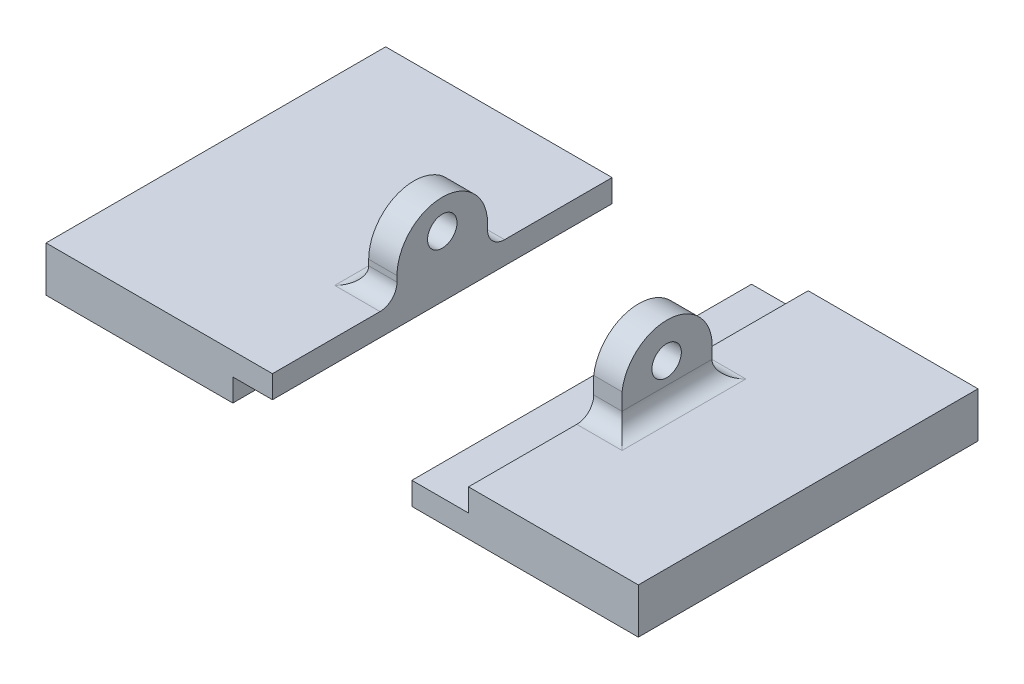
from build123d import *

# Parameters (mm, degrees)
SKETCH1_W             = 20
SKETCH1_H             = 30
BOSS_EXTRUDE2_DEPTH   = 4
BOSS_EXTRUDE2_2_DEPTH = 4
SKETCH2_W             = 30
SKETCH2_H             = 2
CUT_EXTRUDE1_DEPTH    = 3.5
SKETCH3_W             = 30
SKETCH3_H             = 2
CUT_EXTRUDE2_DEPTH    = 5
SKETCH4_R             = 1.3
BOSS_EXTRUDE3_DEPTH   = 2.5
SKETCH5_R             = 1.3
BOSS_EXTRUDE4_DEPTH   = 2.5
FILLET1_R             = 1.5
FILLET2_R             = 1.5


with BuildPart() as part:
    # Sketch1 → Boss-Extrude2 (new body)
    with BuildSketch(Plane(origin=(0, 0, 0), x_dir=(1, 0, 0), z_dir=(0, 1, 0))):
        with Locations((-10, -2.883211679)):
            Rectangle(SKETCH1_W, SKETCH1_H)
    extrude(amount=BOSS_EXTRUDE2_DEPTH)

    # Sketch2 → Cut-Extrude1 (cut)
    with BuildSketch(Plane(origin=(0, 0, 0), x_dir=(0, 0, -1), z_dir=(1, 0, 0))):
        with Locations((-2.883211679, 1)):
            Rectangle(SKETCH2_W, SKETCH2_H)
    extrude(amount=-CUT_EXTRUDE1_DEPTH, mode=Mode.SUBTRACT)

    # Sketch4 → Boss-Extrude3 (add)
    with BuildSketch(Plane(origin=(0, 0, 0), x_dir=(0, 0, -1), z_dir=(1, 0, 0))):
        with BuildLine():
            Line((-6.883211679, 4), (1.116788321, 4))
            Line((1.116788321, 4), (1.116788321, 6))
            ThreePointArc((1.116788321, 6), (-2.883211679, 10), (-6.883211679, 6))
            Line((-6.883211679, 6), (-6.883211679, 4))
        make_face()
        with Locations((-2.883211679, 7.4)):
            Circle(SKETCH4_R, mode=Mode.SUBTRACT)
    extrude(amount=-BOSS_EXTRUDE3_DEPTH)

    # Fillet1
    fillet1_edges = [part.edges().sort_by_distance(p)[0] for p in [
        (-1.25, 4, 6.883211679),
        (-2.5, 4, 2.883211679),
        (-1.25, 4, -1.116788321),
    ]]
    fillet(fillet1_edges, radius=FILLET1_R)


with BuildPart() as body_2:
    # Sketch1 → Boss-Extrude2 2 (new body)
    with BuildSketch(Plane(origin=(0, 0, 0), x_dir=(1, 0, 0), z_dir=(0, 1, 0))):
        with Locations((22.313591297, -2.883211679)):
            Rectangle(SKETCH1_W, SKETCH1_H)
    extrude(amount=BOSS_EXTRUDE2_2_DEPTH)

    # Sketch3 → Cut-Extrude2 (cut)
    with BuildSketch(Plane.ZY.offset(-12.313591297)):
        with Locations((2.883211679, 3)):
            Rectangle(SKETCH3_W, SKETCH3_H)
    extrude(amount=-CUT_EXTRUDE2_DEPTH, mode=Mode.SUBTRACT)

    # Sketch5 → Boss-Extrude4 (add)
    with BuildSketch(Plane.ZY.offset(-17.313591297)):
        with BuildLine():
            Line((-1.116788321, 4), (6.821434693, 4))
            Line((6.821434693, 4), (6.821434693, 6.992277877))
            ThreePointArc((6.821434693, 6.992277877), (2.356184247, 10.465250445), (-1.116788321, 6))
            Line((-1.116788321, 6), (-1.116788321, 4))
        make_face()
        with Locations((2.883211679, 7.4)):
            Circle(SKETCH5_R, mode=Mode.SUBTRACT)
    extrude(amount=-BOSS_EXTRUDE4_DEPTH)

    # Fillet2
    fillet2_edges = [body_2.edges().sort_by_distance(p)[0] for p in [
        (18.563591297, 4, -1.116788321),
        (19.813591297, 4, 2.852323186),
        (18.563591297, 4, 6.821434693),
    ]]
    fillet(fillet2_edges, radius=FILLET2_R)


solid = Compound([part.part, body_2.part])
